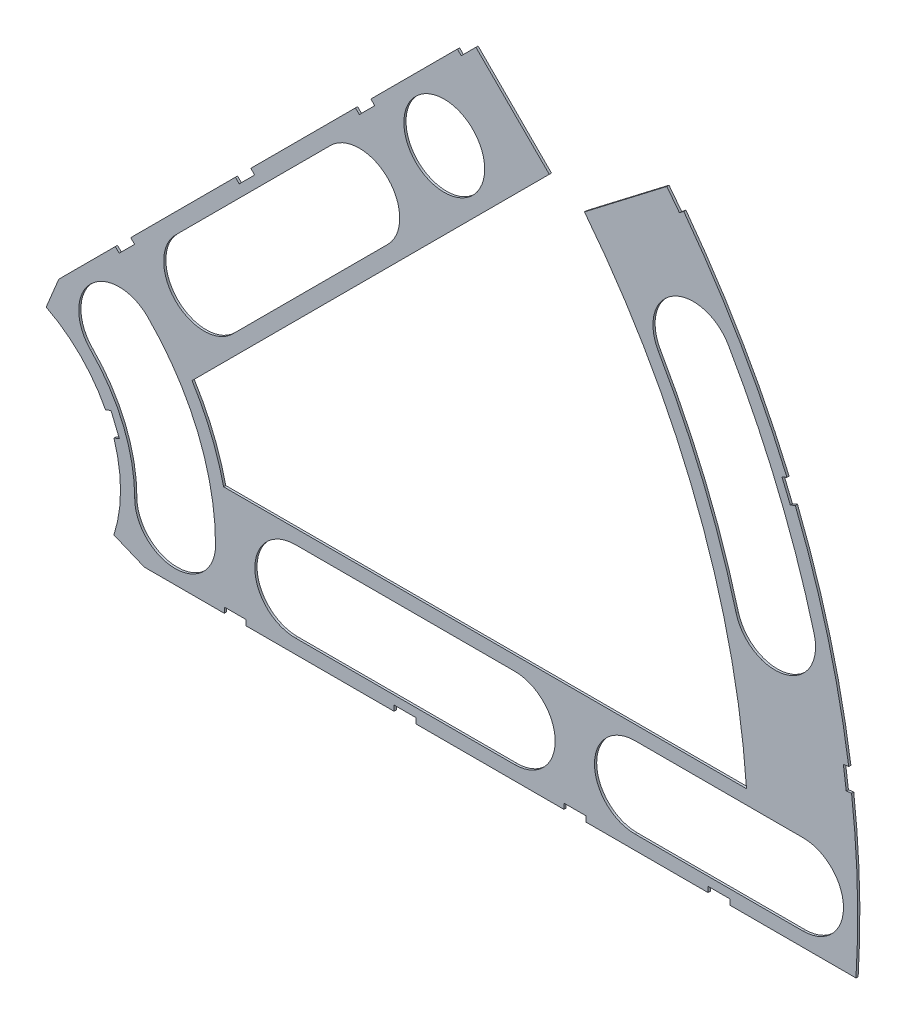
from build123d import *

# Parameters (mm, degrees)
BOSS_EXTRUDE1_DEPTH = 0.254
SKETCH2_R           = 4.699
CUT_EXTRUDE1_DEPTH  = 1.254
SKETCH3_W           = 2.54
SKETCH3_H           = 0.635
CUT_EXTRUDE2_DEPTH  = 1.254
CUT_EXTRUDE4_DEPTH  = 1.254
CUT_EXTRUDE5_DEPTH  = 1.254


with BuildPart() as part:
    # Sketch1 → Boss-Extrude1 (new body)
    with BuildSketch(Plane.XY):
        with BuildLine():
            Line((67.21146711, 76.191723231), (8.696654013, 17.676910134))
            Line((8.696654013, 17.676910134), (7.228954972, 14.133571205))
            ThreePointArc((7.228954972, 14.133571205), (14.666587579, 6.075099489), (15.105587123, -4.88230096))
            Line((15.105587123, -4.88230096), (18.648926052, -6.35))
            Line((18.648926052, -6.35), (101.401368334, -6.35))
            ThreePointArc((101.401368334, -6.35), (93.866160503, 38.880636728), (67.21146711, 76.191723231))
        make_face()
        with BuildLine():
            Line((88.672924278, 6.35), (27.86051193, 6.35))
            ThreePointArc((27.86051193, 6.35), (26.399857642, 10.93517908), (24.190484974, 15.210228852))
            Line((24.190484974, 15.210228852), (67.191354125, 58.211098004))
            ThreePointArc((67.191354125, 58.211098004), (82.13289044, 34.020557137), (88.672924278, 6.35))
        make_face(mode=Mode.SUBTRACT)
    extrude(amount=BOSS_EXTRUDE1_DEPTH)

    # Sketch2 → Cut-Extrude1 (cut, through all)
    with BuildSketch(Plane.XY.offset(0.254)):
        with Locations((22.225, 0)):
            Circle(SKETCH2_R)
        with Locations((36.195, 0)):
            Circle(SKETCH2_R)
        with Locations((61.722, 0)):
            Circle(SKETCH2_R)
        with Locations((75.692, 0)):
            Circle(SKETCH2_R)
        with Locations((95.25, 0)):
            Circle(SKETCH2_R)
        with Locations((15.715448212, 15.715448212)):
            Circle(SKETCH2_R)
        with Locations((25.593729945, 25.593729945)):
            Circle(SKETCH2_R)
        with Locations((43.644044748, 43.644044748)):
            Circle(SKETCH2_R)
        with Locations((53.522326482, 53.522326482)):
            Circle(SKETCH2_R)
        with Locations((92.004434954, 24.652514046)):
            Circle(SKETCH2_R)
        with Locations((82.48891971, 47.625)):
            Circle(SKETCH2_R)
        with Locations((67.351920908, 67.351920908)):
            Circle(SKETCH2_R)
    extrude(amount=-CUT_EXTRUDE1_DEPTH, mode=Mode.SUBTRACT)

    # Sketch3 → Cut-Extrude2 (cut, through all)
    with BuildSketch(Plane.XY.offset(0.254)):
        Polygon((15.266435406, 24.246691527), (17.06248663, 26.042742751), (17.511499436, 25.593729945), (15.715448212, 23.797678721), align=None)
        Polygon((44.991083167, 53.971339288), (43.195031942, 52.175288063), (43.644044748, 51.726275257), (45.440095973, 53.522326482), align=None)
        with Locations((29.21, -6.0325)):
            Rectangle(SKETCH3_W, SKETCH3_H)
        with Locations((68.707, -6.0325)):
            Rectangle(SKETCH3_W, SKETCH3_H)
        Polygon((29.230733674, 38.210989795), (31.026784898, 40.007041019), (31.475797704, 39.558028213), (29.67974648, 37.761976989), align=None)
        Polygon((56.845021246, 65.825277367), (55.048970022, 64.029226143), (55.497982828, 63.580213337), (57.294034052, 65.376264561), align=None)
        with Locations((48.9585, -6.0325)):
            Rectangle(SKETCH3_W, SKETCH3_H)
        with Locations((85.471, -6.0325)):
            Rectangle(SKETCH3_W, SKETCH3_H)
        Polygon((99.935462164, 14.437711971), (100.266998693, 11.919442024), (101.526133667, 12.085210288), (101.194597138, 14.603480236), align=None)
        Polygon((93.765504959, 37.464305742), (94.938831965, 37.950313702), (93.966816047, 40.296967714), (92.793489041, 39.810959755), align=None)
        Polygon((79.327792988, 62.471156422), (80.874047017, 60.456038938), (81.88160576, 61.229165953), (80.33535173, 63.244283437), align=None)
        Polygon((13.593916116, 7.005422516), (14.565932035, 4.658768503), (15.739259041, 5.144776462), (14.767243123, 7.491430475), align=None)
    extrude(amount=-CUT_EXTRUDE2_DEPTH, mode=Mode.SUBTRACT)

    # Sketch6 → Cut-Extrude4 (cut, through all)
    with BuildSketch(Plane.XY.offset(0.254)):
        with BuildLine():
            Line((22.27103518, 28.91642471), (40.321349984, 46.966739513))
            ThreePointArc((40.321349984, 46.966739513), (46.966739513, 46.966739513), (46.966739513, 40.321349984))
            Line((46.966739513, 40.321349984), (28.91642471, 22.27103518))
            ThreePointArc((28.91642471, 22.27103518), (22.27103518, 22.27103518), (22.27103518, 28.91642471))
        make_face()
        with BuildLine():
            Line((61.722, -4.699), (36.195, -4.699))
            ThreePointArc((36.195, -4.699), (31.496, 0), (36.195, 4.699))
            Line((36.195, 4.699), (61.722, 4.699))
            ThreePointArc((61.722, 4.699), (66.421, 0), (61.722, -4.699))
        make_face()
        with BuildLine():
            Line((95.25, -4.699), (75.692, -4.699))
            ThreePointArc((75.692, -4.699), (70.993, 0), (75.692, 4.699))
            Line((75.692, 4.699), (95.25, 4.699))
            ThreePointArc((95.25, 4.699), (99.949, 0), (95.25, -4.699))
        make_face()
        with BuildLine():
            ThreePointArc((26.924, 0), (24.874532533, 10.303368733), (19.038142977, 19.038142977))
            ThreePointArc((19.038142977, 19.038142977), (12.392753447, 19.038142977), (12.392753447, 12.392753447))
            ThreePointArc((12.392753447, 12.392753447), (16.191912687, 6.706909836), (17.526, 0))
            ThreePointArc((17.526, 0), (22.225, -4.699), (26.924, 0))
        make_face()
        with BuildLine():
            ThreePointArc((96.543320412, 25.868704739), (92.340835395, 38.248826381), (86.558373083, 49.9745))
            ThreePointArc((86.558373083, 49.9745), (80.13941971, 51.694453372), (78.419466338, 45.2755))
            ThreePointArc((78.419466338, 45.2755), (83.658215548, 34.652367484), (87.465549496, 23.436323353))
            ThreePointArc((87.465549496, 23.436323353), (93.220625647, 20.113628588), (96.543320412, 25.868704739))
        make_face()
    extrude(amount=-CUT_EXTRUDE4_DEPTH, mode=Mode.SUBTRACT)

    # Sketch5 → Cut-Extrude5 (cut, through all)
    with BuildSketch(Plane.XY.offset(0.254)):
        Polygon((55.857193073, 66.633500418), (68.493252435, 53.997441057), (81.501289898, 63.978859263), (67.351920908, 78.128228253), align=None)
    extrude(amount=-CUT_EXTRUDE5_DEPTH, mode=Mode.SUBTRACT)


solid = part.part
